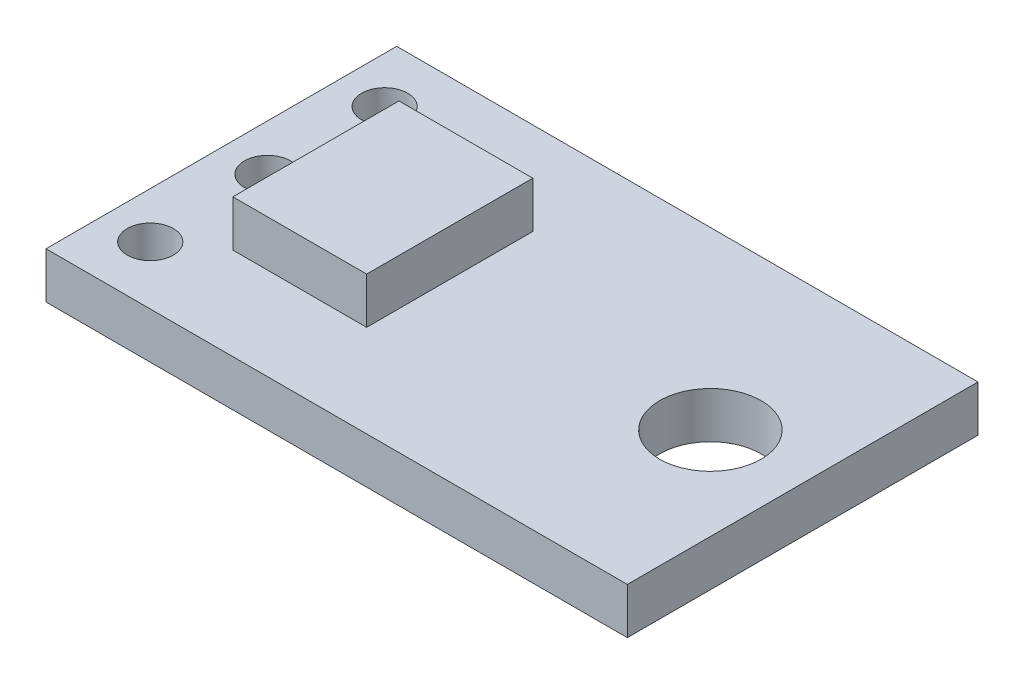
from build123d import *

# Parameters (mm, degrees)
SKETCH1_W           = 17
SKETCH1_H           = 10
BOSS_EXTRUDE1_DEPTH = 1
SKETCH2_W           = 3
SKETCH2_H           = 4
BOSS_EXTRUDE2_DEPTH = 1
SKETCH3_W           = 22.308498818
SKETCH3_H           = 11.48116176
SKETCH3_W_2         = 12.6
SKETCH3_H_2         = 7.6
CUT_EXTRUDE1_DEPTH  = 1
SKETCH4_R           = 0.5
SKETCH4_R_2         = 1.1
CUT_EXTRUDE2_DEPTH  = 1
SKETCH5_W           = 3.647171716
SKETCH5_H           = 4.834622973
SKETCH5_W_2         = 2.9
SKETCH5_H_2         = 3.6
CUT_EXTRUDE3_DEPTH  = 1


with BuildPart() as part:
    # Sketch1 → Boss-Extrude1 (new body)
    with BuildSketch(Plane(origin=(0, 0, 0), x_dir=(1, 0, 0), z_dir=(0, 1, 0))):
        with Locations((-16, 13.384146341)):
            Rectangle(SKETCH1_W, SKETCH1_H)
    extrude(amount=BOSS_EXTRUDE1_DEPTH)

    # Sketch2 → Boss-Extrude2 (add)
    with BuildSketch(Plane(origin=(0, 1, 0), x_dir=(1, 0, 0), z_dir=(0, 1, 0))):
        with Locations((-21, 13.384146341)):
            Rectangle(SKETCH2_W, SKETCH2_H)
    extrude(amount=BOSS_EXTRUDE2_DEPTH)

    # Sketch3 → Cut-Extrude1 (cut)
    with BuildSketch(Plane(origin=(0, 1, 0), x_dir=(1, 0, 0), z_dir=(0, 1, 0))):
        with Locations((-18.026856575, 13.593370246)):
            Rectangle(SKETCH3_W, SKETCH3_H)
        with Locations((-18.2, 13.384146341)):
            Rectangle(SKETCH3_W_2, SKETCH3_H_2, mode=Mode.SUBTRACT)
    extrude(amount=-CUT_EXTRUDE1_DEPTH, mode=Mode.SUBTRACT)

    # Sketch4 → Cut-Extrude2 (cut)
    with BuildSketch(Plane(origin=(0, 1, 0), x_dir=(1, 0, 0), z_dir=(0, 1, 0))):
        with Locations((-23.5, 13.384146341)):
            Circle(SKETCH4_R)
        with Locations((-23.5, 15.924146341)):
            Circle(SKETCH4_R)
        with Locations((-23.5, 10.844146341)):
            Circle(SKETCH4_R)
        with Locations((-13.9, 13.384146341)):
            Circle(SKETCH4_R_2)
    extrude(amount=-CUT_EXTRUDE2_DEPTH, mode=Mode.SUBTRACT)

    # Sketch5 → Cut-Extrude3 (cut)
    with BuildSketch(Plane(origin=(0, 2, 0), x_dir=(1, 0, 0), z_dir=(0, 1, 0))):
        with Locations((-20.925831492, 13.474507318)):
            Rectangle(SKETCH5_W, SKETCH5_H)
        with Locations((-21, 13.384146341)):
            Rectangle(SKETCH5_W_2, SKETCH5_H_2, mode=Mode.SUBTRACT)
    extrude(amount=-CUT_EXTRUDE3_DEPTH, mode=Mode.SUBTRACT)


solid = part.part
